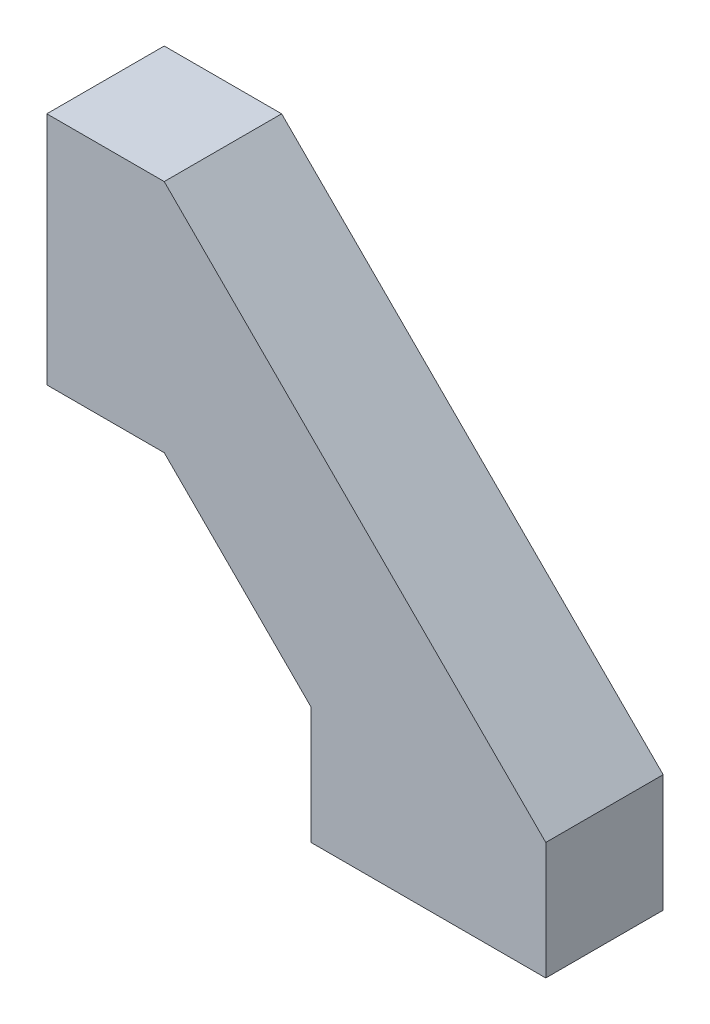
from build123d import *

# Parameters (mm, degrees)
SKETCH1_W           = 8
SKETCH1_H           = 4
SKETCH1_W_2         = 4
SKETCH1_H_2         = 8
BOSS_EXTRUDE1_DEPTH = 4


with BuildPart() as part:
    # Sketch1 → Boss-Extrude1 (new body)
    with BuildSketch(Plane.XY):
        Polygon((-13, 9), (-8, 4), (0, 4), (-5, 9), align=None)
        with Locations((-4, 2)):
            Rectangle(SKETCH1_W, SKETCH1_H)
        Polygon((-13, 17), (-13, 9), (-5, 9), align=None)
        with Locations((-15, 13)):
            Rectangle(SKETCH1_W_2, SKETCH1_H_2)
    extrude(amount=BOSS_EXTRUDE1_DEPTH)


solid = part.part
